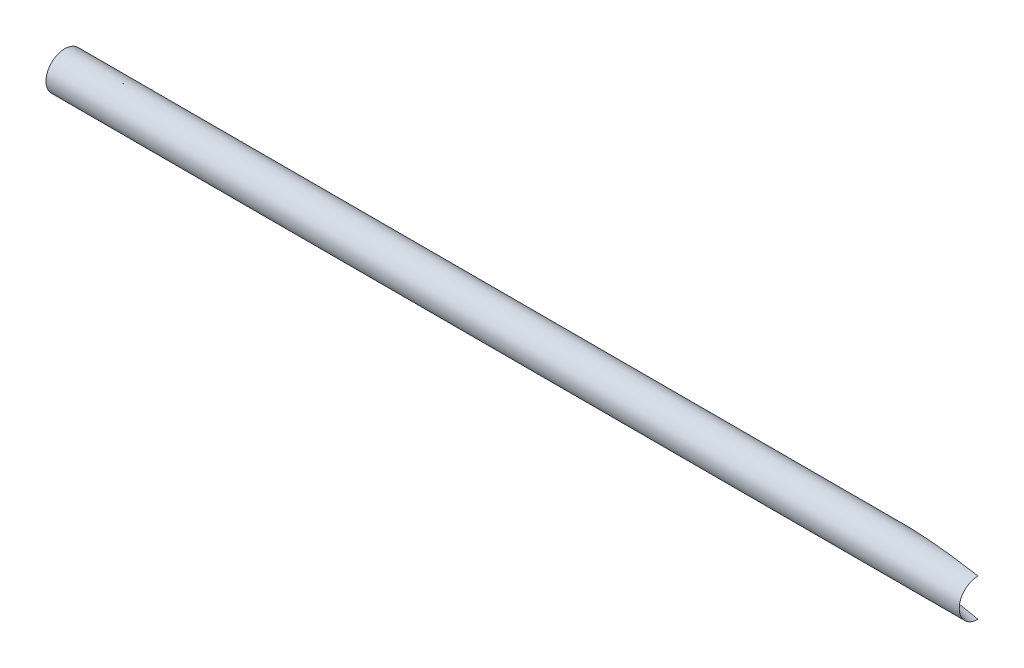
from build123d import *

# Parameters (mm, degrees)
SKETCH13_R                          = 9.525
SKETCH13_R_2                        = 6.35
ROUND_75IN_X_125IN_SIDEWALL_1_DEPTH = 463.55
SKETCH15_R                          = 9.525
SKETCH15_R_2                        = 6.35
CUT_EXTRUDE1_DEPTH                  = 485.776105476


with BuildPart() as part:
    # Sketch13 → Round .75IN X .125IN SIDEWALL(1) (new body)
    with BuildSketch(Plane(origin=(231.775, 0, 0), x_dir=(0, -1, 0), z_dir=(-1, 0, 0))):
        Circle(SKETCH13_R)
        Circle(SKETCH13_R_2, mode=Mode.SUBTRACT)
    extrude(amount=ROUND_75IN_X_125IN_SIDEWALL_1_DEPTH)

    # Sketch15 → Cut-Extrude1 (cut, through all, along a direction that is not the sketch's normal)
    with BuildSketch(Plane(origin=(231.775, 0, 0), x_dir=(0, 0, -1), z_dir=(1, 0, 0))):
        with Locations(Location((0, 0, 0), (0, 0, 270))):
            Circle(SKETCH15_R)
        with Locations(Location((0, 0, 0), (0, 0, 90))):
            Circle(SKETCH15_R_2, mode=Mode.SUBTRACT)
        with Locations(Location((0, 0, 0), (0, 0, 90))):
            Circle(SKETCH15_R_2)
    extrude(amount=-CUT_EXTRUDE1_DEPTH, dir=(0.956304756, 0, 0.292371705), mode=Mode.SUBTRACT)


solid = part.part
